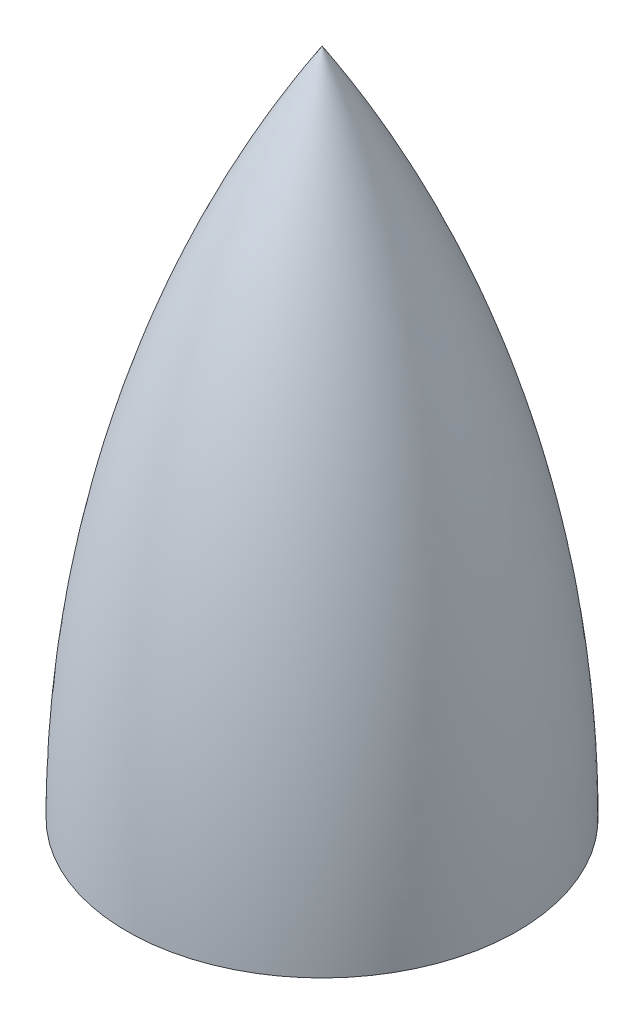
from build123d import *


with BuildPart() as part:
    # Sketch1 → Revolve1 (revolve)
    with BuildSketch(Plane.XY):
        with BuildLine():
            Line((0, 0), (3500, 0))
            ThreePointArc((3500, 0), (2607.16000035, 6250.005000102), (0, 12000))
            Line((0, 12000), (0, 0))
        make_face()
    revolve(axis=Axis((0, 0, 0), (0, 1, 0)))


solid = part.part
